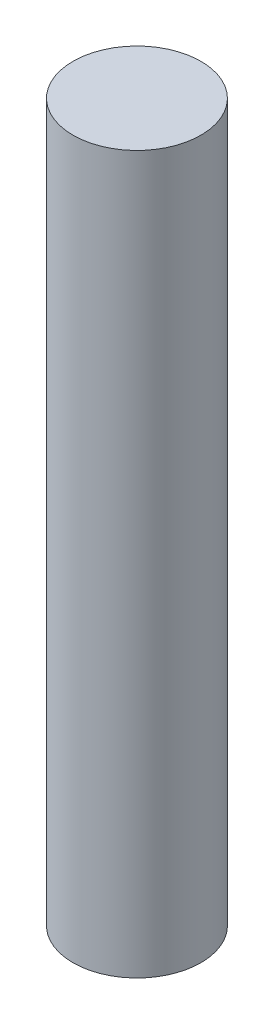
from build123d import *

# Parameters (mm, degrees)
SKETCH1_R           = 12.5
BOSS_EXTRUDE1_DEPTH = 140


with BuildPart() as part:
    # Sketch1 → Boss-Extrude1 (new body)
    with BuildSketch(Plane(origin=(0, 0, 0), x_dir=(1, 0, 0), z_dir=(0, 1, 0))):
        Circle(SKETCH1_R)
    extrude(amount=BOSS_EXTRUDE1_DEPTH)


solid = part.part
